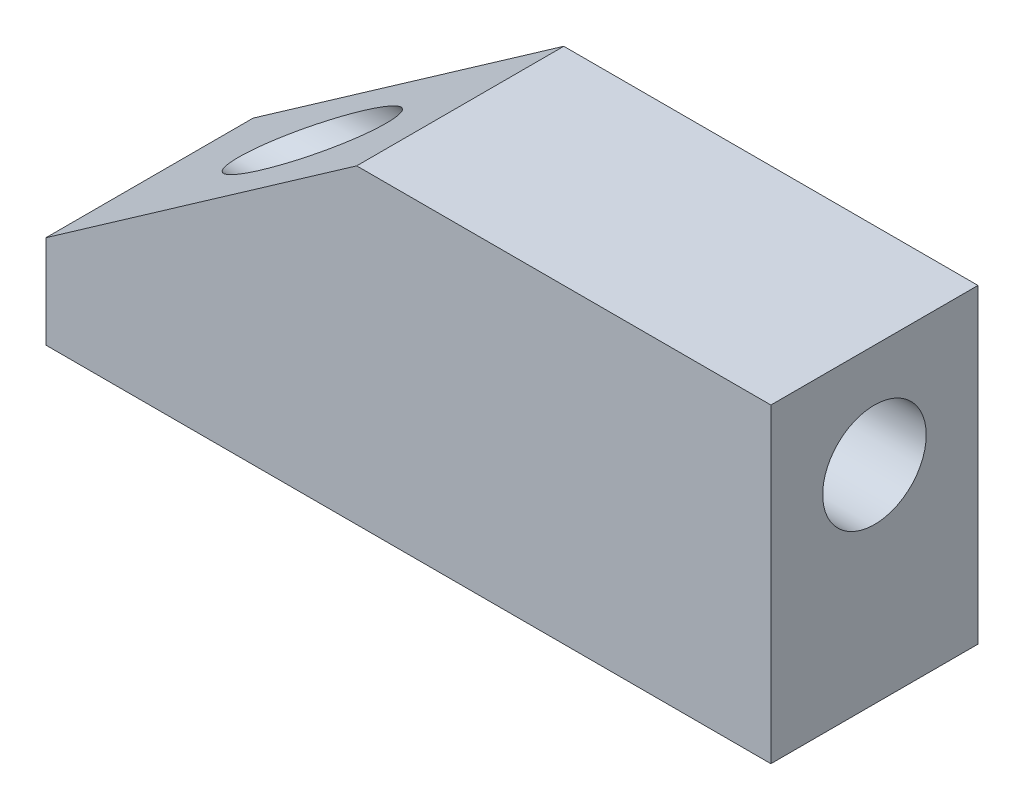
from build123d import *

# Parameters (mm, degrees)
EXTRUDE_1_DEPTH     = 10
SKETCH_2_R          = 2.5
CUT_EXTRUDE_1_DEPTH = 36


with BuildPart() as part:
    # 草图1 → 凸台-拉伸1 (new body)
    with BuildSketch(Plane.XY):
        Polygon((48.487404746, 20.427900409), (48.487404746, 24.924787336), (63.487404746, 35.427900409), (83.487404746, 35.427900409), (83.487404746, 20.427900409), align=None)
    extrude(amount=EXTRUDE_1_DEPTH)

    # 草图2 → 切除-拉伸1 (cut, through all)
    with BuildSketch(Plane(origin=(83.487404746, 0, 0), x_dir=(0, 0, -1), z_dir=(1, 0, 0))):
        with Locations((-5, 30.427900409)):
            Circle(SKETCH_2_R)
    extrude(amount=-CUT_EXTRUDE_1_DEPTH, mode=Mode.SUBTRACT)


solid = part.part
